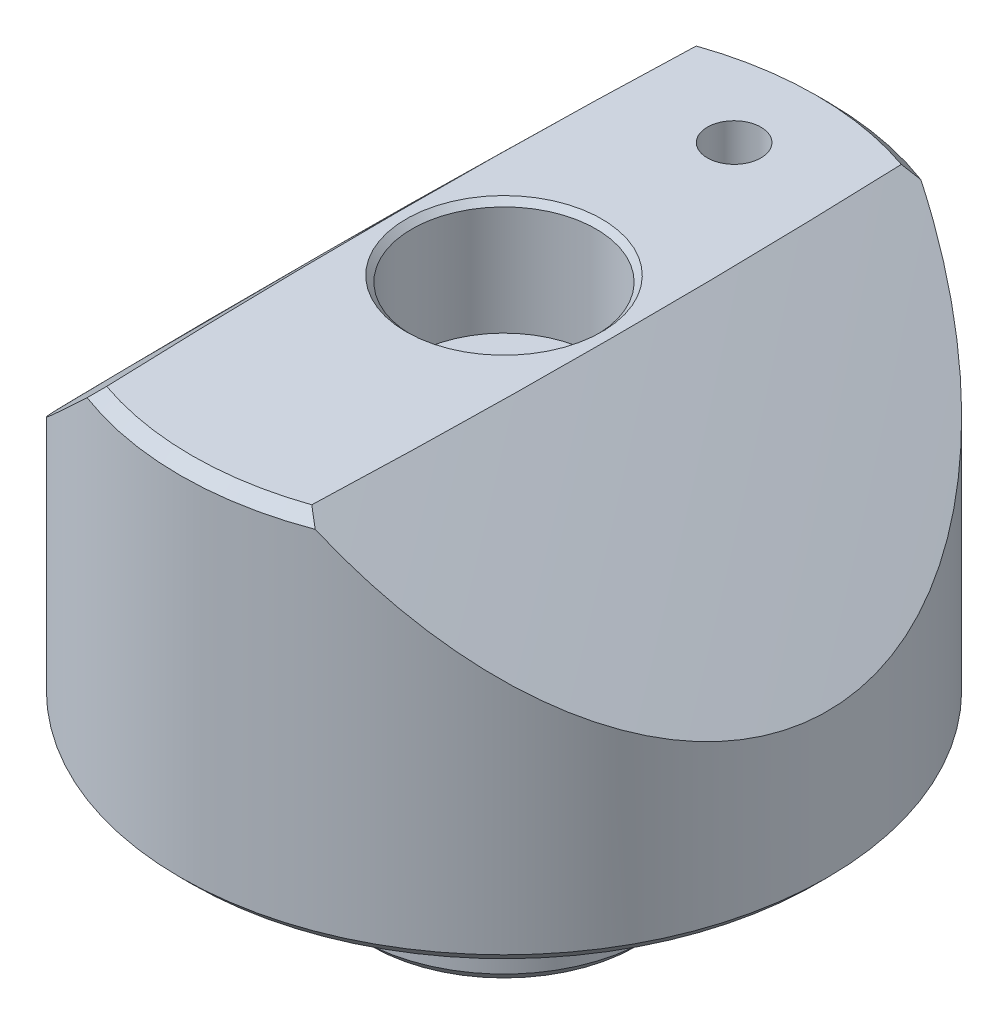
from build123d import *

# Parameters (mm, degrees)
SKETCH1_R               = 14.2875
BOSS_EXTRUDE1_DEPTH     = 16.383
SKETCH2_R               = 6.35
BOSS_EXTRUDE2_DEPTH     = 6.35
SKETCH4_R               = 1.1811
CUT_EXTRUDE1_DEPTH      = 23.733
CHAMFER1_SIZE           = 0.508
CUT_EXTRUDE2_DEPTH      = 18.923
CUT_REVOLVE1_ANGLE      = 5
SKETCH7_R               = 0.635
F_1_4_20_TAPPED_HOLE1_D = 5.1054
HOLE1_D                 = 8.128
HOLE1_DEPTH             = 5.08
CHAMFER2_SIZE           = 0.254


with BuildPart() as part:
    # Sketch1 → Boss-Extrude1 (new body)
    with BuildSketch(Plane(origin=(0, 0, 0), x_dir=(1, 0, 0), z_dir=(0, 1, 0))):
        with Locations(Location((0, 0, 0), (0, 0, 270))):  # turned: the seam where the file's is
            Circle(SKETCH1_R)
    extrude(amount=BOSS_EXTRUDE1_DEPTH)

    # Sketch2 → Boss-Extrude2 (add)
    with BuildSketch(Plane.XZ):
        with Locations(Location((0, 0, 0), (0, 0, 90))):  # turned: the seam where the file's is
            Circle(SKETCH2_R)
    extrude(amount=BOSS_EXTRUDE2_DEPTH)

    # Sketch4 → Cut-Extrude1 (cut, through all)
    with BuildSketch(Plane(origin=(0, 16.383, 0), x_dir=(1, 0, 0), z_dir=(0, 1, 0))):
        with Locations(Location((0, 10.16, 0), (0, 0, 270))):  # turned: the seam where the file's is
            Circle(SKETCH4_R)
    extrude(amount=-CUT_EXTRUDE1_DEPTH, mode=Mode.SUBTRACT)

    # Chamfer1
    chamfer1_edges = [part.edges().sort_by_distance(p)[0] for p in [
        (0, 0, -14.2875),
        (0, 16.383, -14.2875),
        (0, -6.35, -6.35),
    ]]
    chamfer(chamfer1_edges, length=CHAMFER1_SIZE)

    # Sketch5 → Cut-Extrude2 (cut, symmetric)
    with BuildSketch(Plane.XY):
        Polygon((-2.548384182, 18.669), (-16.088719044, 5.128665138), (-16.088719044, 23.827435377), (16.088719044, 23.827435377), (16.088719044, 5.128665138), (2.548384182, 18.669), align=None)
    extrude(amount=CUT_EXTRUDE2_DEPTH, both=True, mode=Mode.SUBTRACT)

    # Sketch6 → Cut-Revolve1 (revolve, symmetric, cut)
    with BuildSketch(Plane.XY) as cut_revolve1_sk:
        with BuildLine():
            Line((0.60449584, 21.537658497), (-20.777423288, 21.537658497))
            Line((-20.777423288, 21.537658497), (-20.777423288, 0.072260804))
            ThreePointArc((-20.777423288, 0.072260804), (-10.249089347, 10.966952825), (0.60449584, 21.537658497))
        make_face()
    cut_revolve1 = revolve(axis=Axis((343.991741396, -341.896241396, 0), (0, 1, 0)), revolution_arc=CUT_REVOLVE1_ANGLE / 2, mode=Mode.SUBTRACT)
    cut_revolve1 = cut_revolve1 + revolve(cut_revolve1_sk.sketch, axis=Axis((343.991741396, -341.896241396, 0), (0, -1, 0)), revolution_arc=CUT_REVOLVE1_ANGLE / 2, mode=Mode.SUBTRACT)

    # Mirror1: Cut-Revolve1 across plane
    add(cut_revolve1.mirror(Plane(origin=(0, 0, 0), x_dir=(0, 0, 1), z_dir=(1, 0, 0))), mode=Mode.SUBTRACT)

    # Sketch7 → Cut-Revolve2 (revolve, cut)
    with BuildSketch(Plane.XY, mode=Mode.PRIVATE) as cut_revolve2_sk:
        with Locations((6.799012806, -0.449012806)):
            Circle(SKETCH7_R)
    revolve(cut_revolve2_sk.sketch.rotate(Axis((0, 16.383, 0), (0, -1, 0)), 90), axis=Axis((0, 16.383, 0), (0, -1, 0)), mode=Mode.SUBTRACT)  # turned: the seam where the file's is

    # 1/4-20 Tapped Hole1 (through all)
    with Locations(Plane(origin=(0, 16.383, 0), x_dir=(1, 0, 0), z_dir=(0, 1, 0))):
        with Locations((0, 0)):
            Hole(F_1_4_20_TAPPED_HOLE1_D / 2)

    # Hole1
    with Locations(Plane(origin=(0, 16.383, 0), x_dir=(1, 0, 0), z_dir=(0, 1, 0))):
        with Locations((0, 0)):
            Hole(HOLE1_D / 2, depth=HOLE1_DEPTH)

    # Chamfer2
    chamfer2_edges = [part.edges().sort_by_distance(p)[0] for p in [
        (2.5527, -6.35, 0),
        (2.5527, 11.303, 0),
        (4.064, 16.383, 0),
    ]]
    chamfer(chamfer2_edges, length=CHAMFER2_SIZE)


solid = part.part
